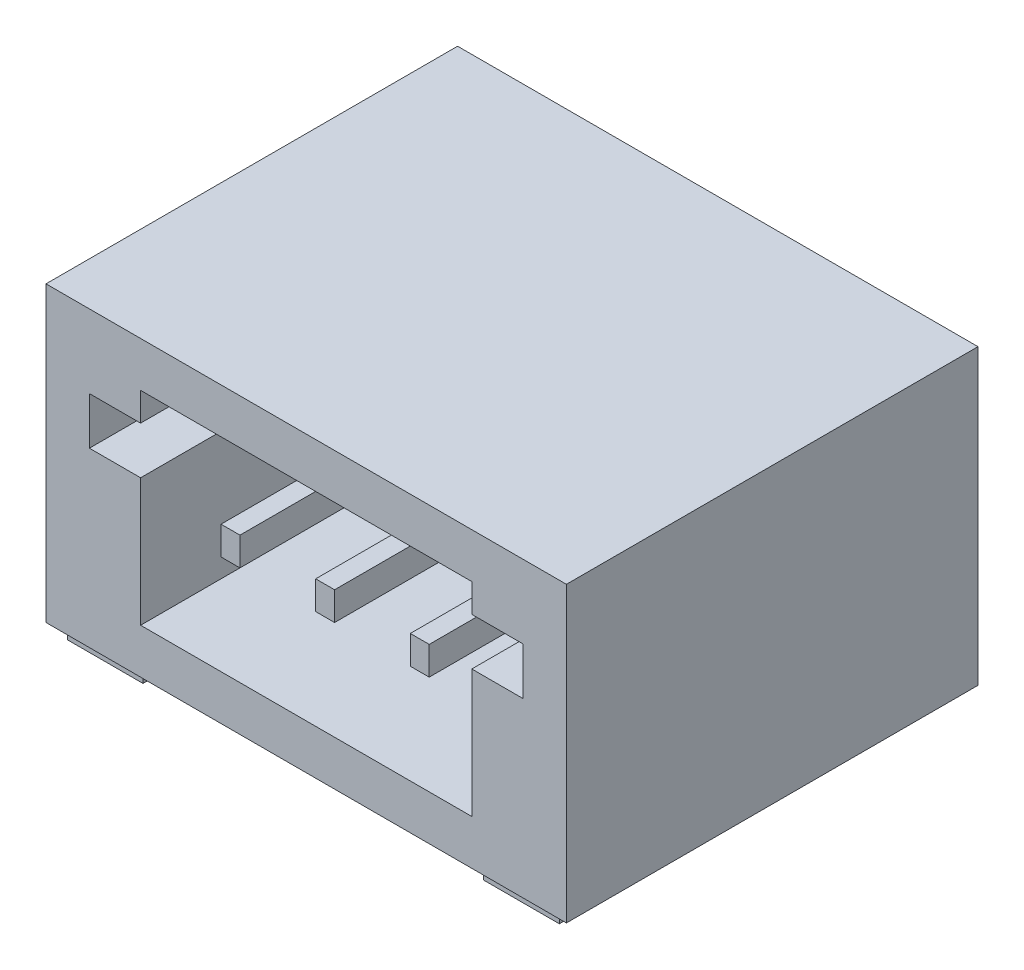
from build123d import *

# Parameters (mm, degrees)
SKETCH_1_W          = 4.35
SKETCH_1_H          = 3.1
EXTRUDE_1_DEPTH     = 5.5
CUT_EXTRUDE_1_DEPTH = 3.7
SKETCH_4_W          = 0.2
SKETCH_4_H          = 0.3
EXTRUDE_2_DEPTH     = 3.5
SKETCH_5_W          = 0.2
SKETCH_5_H          = 0.85
SKETCH_5_W_2        = 0.8
SKETCH_5_H_2        = 1.3
EXTRUDE_3_DEPTH     = 0.12


with BuildPart() as part:
    # 草图1 → 凸台-拉伸1 (new body)
    with BuildSketch(Plane(origin=(0, 0, 0), x_dir=(0, 0, -1), z_dir=(1, 0, 0))):
        with Locations((2.175, 1.55)):
            Rectangle(SKETCH_1_W, SKETCH_1_H)
    extrude(amount=EXTRUDE_1_DEPTH)

    # 草图2 → 切除-拉伸1 (cut)
    with BuildSketch(Plane.XY):
        Polygon((1, 0.475), (4.5, 0.475), (4.5, 1.825), (5.041281958, 1.825), (5.041281958, 2.325), (4.5, 2.325), (4.5, 2.625), (1, 2.625), (1, 2.325), (0.458718042, 2.325), (0.458718042, 1.825), (1, 1.825), align=None)
    extrude(amount=-CUT_EXTRUDE_1_DEPTH, mode=Mode.SUBTRACT)

    # 草图4 → 凸台-拉伸2 (add)
    with BuildSketch(Plane.XY.offset(-3.7)):
        with Locations((2.75, 1.475)):
            Rectangle(SKETCH_4_W, SKETCH_4_H)
        with Locations((1.75, 1.475)):
            Rectangle(SKETCH_4_W, SKETCH_4_H)
        with Locations((3.75, 1.475)):
            Rectangle(SKETCH_4_W, SKETCH_4_H)
    extrude(amount=EXTRUDE_2_DEPTH)

    # 草图5 → 凸台-拉伸3 (add)
    with BuildSketch(Plane.XZ):
        with Locations((2.75, -4.6)):
            Rectangle(SKETCH_5_W, SKETCH_5_H)
        with Locations((0.55, -0.725)):
            Rectangle(SKETCH_5_W_2, SKETCH_5_H_2)
        with Locations((1.75, -4.6)):
            Rectangle(SKETCH_5_W, SKETCH_5_H)
        with Locations((3.75, -4.6)):
            Rectangle(SKETCH_5_W, SKETCH_5_H)
        with Locations((4.95, -0.725)):
            Rectangle(SKETCH_5_W_2, SKETCH_5_H_2)
    extrude(amount=EXTRUDE_3_DEPTH)


solid = part.part
